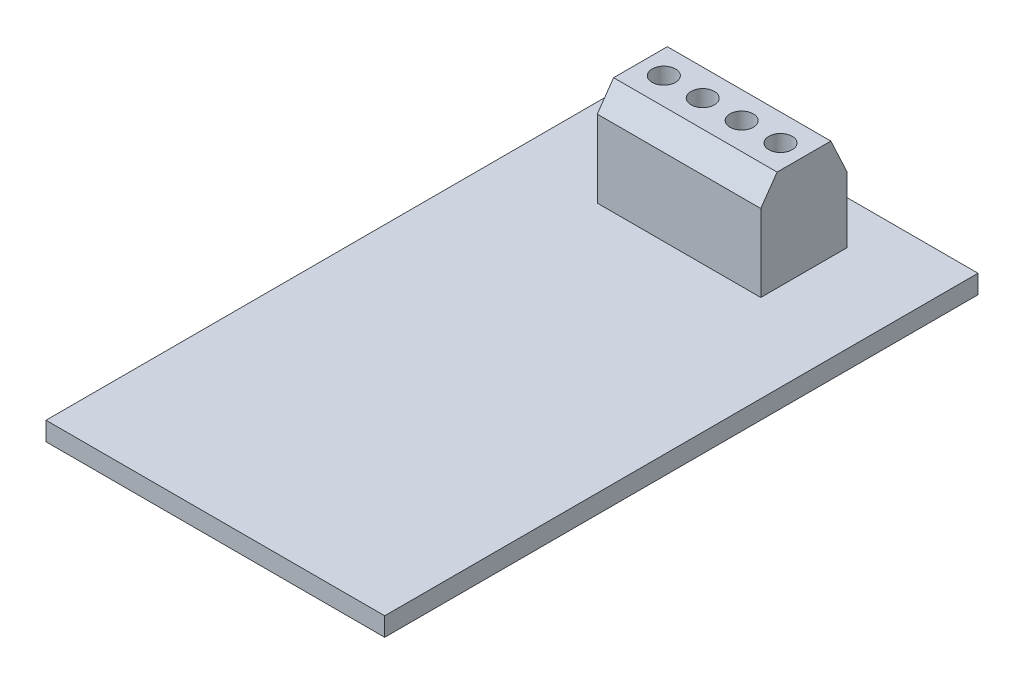
from build123d import *

# Parameters (mm, degrees)
CROQUIS1_W              = 29
CROQUIS1_H              = 50.8
SALIENTE_EXTRUIR1_DEPTH = 1.6
SALIENTE_EXTRUIR2_DEPTH = 7
CROQUIS3_R              = 1
CORTAR_EXTRUIR1_DEPTH   = 3


with BuildPart() as part:
    # Croquis1 → Saliente-Extruir1 (new body)
    with BuildSketch(Plane(origin=(0, 0, 0), x_dir=(1, 0, 0), z_dir=(0, 1, 0))):
        Rectangle(CROQUIS1_W, CROQUIS1_H)
    extrude(amount=SALIENTE_EXTRUIR1_DEPTH)

    # Croquis2 → Saliente-Extruir2 (add, symmetric)
    with BuildSketch(Plane(origin=(0, 0, 0), x_dir=(0, 0, -1), z_dir=(1, 0, 0))):
        Polygon((14.3, 1.6), (14.3, 8.2), (15.7, 10.2), (20.3, 10.2), (21.7, 7.2), (21.7, 1.6), align=None)
    extrude(amount=SALIENTE_EXTRUIR2_DEPTH, both=True)

    # Croquis3 → Cortar-Extruir1 (cut)
    with BuildSketch(Plane(origin=(0, 10.2, 0), x_dir=(1, 0, 0), z_dir=(0, 1, 0))):
        with Locations((-5, 18)):
            Circle(CROQUIS3_R)
        with Locations((-1.67, 18)):
            Circle(CROQUIS3_R)
        with Locations((1.66, 18)):
            Circle(CROQUIS3_R)
        with Locations((4.99, 18)):
            Circle(CROQUIS3_R)
    extrude(amount=-CORTAR_EXTRUIR1_DEPTH, mode=Mode.SUBTRACT)


solid = part.part
